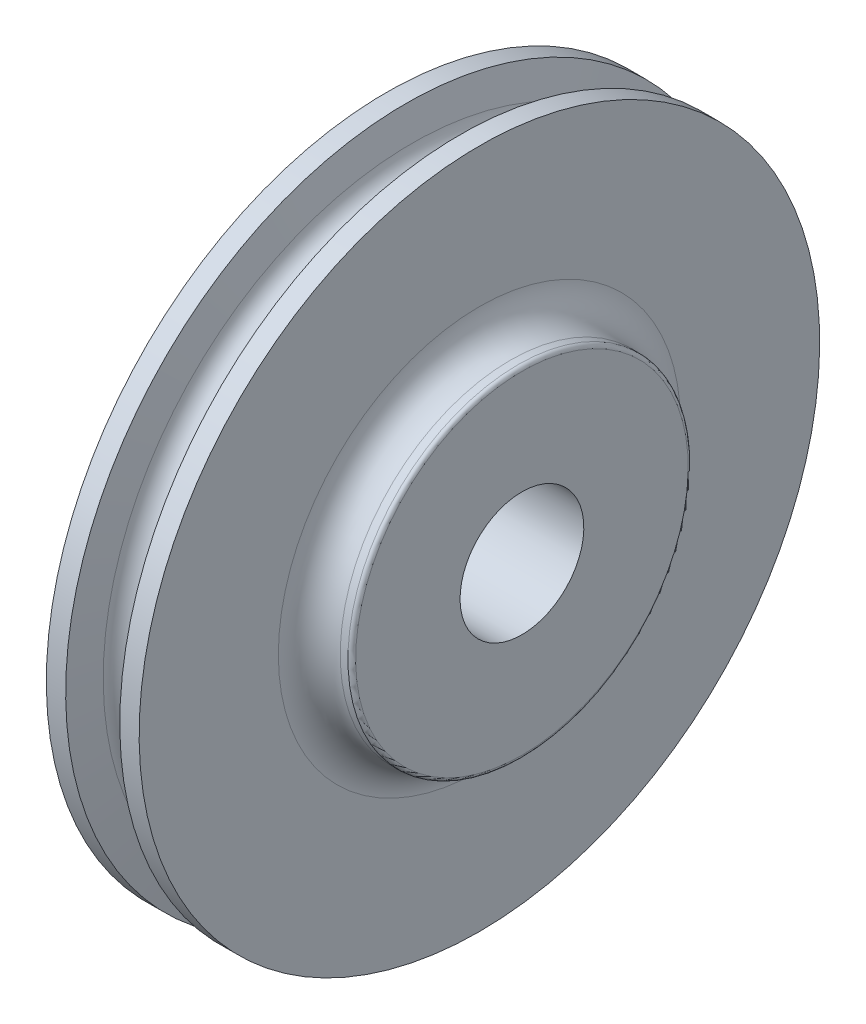
from build123d import *

# Parameters (mm, degrees)
SKETCH2_R          = 25.40635
CUT_EXTRUDE1_DEPTH = 74.025


with BuildPart() as part:
    # Sketch1 → Revolve1 (revolve)
    with BuildSketch(Plane.XY, mode=Mode.PRIVATE) as revolve1_sk:
        with BuildLine():
            Line((19.05, 139.7), (19.05, 82.55))
            ThreePointArc((19.05, 82.55), (22.769743879, 73.569743879), (31.75, 69.85))
            Line((31.75, 69.85), (34.925, 69.85))
            ThreePointArc((34.925, 69.85), (36.047532015, 69.385032015), (36.5125, 68.2625))
            Line((36.5125, 68.2625), (36.5125, 0))
            Line((36.5125, 0), (-36.5125, 0))
            Line((-36.5125, 0), (-36.5125, 68.2625))
            ThreePointArc((-36.5125, 68.2625), (-36.047532015, 69.385032015), (-34.925, 69.85))
            Line((-34.925, 69.85), (-31.75, 69.85))
            ThreePointArc((-31.75, 69.85), (-22.769743879, 73.569743879), (-19.05, 82.55))
            Line((-19.05, 82.55), (-19.05, 139.7))
            Line((-19.05, 139.7), (-11.1125, 139.7))
            Line((-11.1125, 139.7), (-8.542828829, 126.8589166))
            ThreePointArc((-8.542828829, 126.8589166), (0, 119.85625), (8.542828829, 126.8589166))
            Line((8.542828829, 126.8589166), (11.1125, 139.7))
            Line((11.1125, 139.7), (19.05, 139.7))
        make_face()
    revolve(revolve1_sk.sketch.rotate(Axis((-36.5125, 0, 0), (1, 0, 0)), 180), axis=Axis((-36.5125, 0, 0), (1, 0, 0)))  # turned: the seam where the file's is

    # Sketch2 → Cut-Extrude1 (cut, through all)
    with BuildSketch(Plane(origin=(36.5125, 0, 0), x_dir=(0, 0, -1), z_dir=(1, 0, 0))):
        with Locations(Location((0, 0, 0), (0, 0, 90))):  # turned: the seam where the file's is
            Circle(SKETCH2_R)
    extrude(amount=-CUT_EXTRUDE1_DEPTH, mode=Mode.SUBTRACT)


solid = part.part
